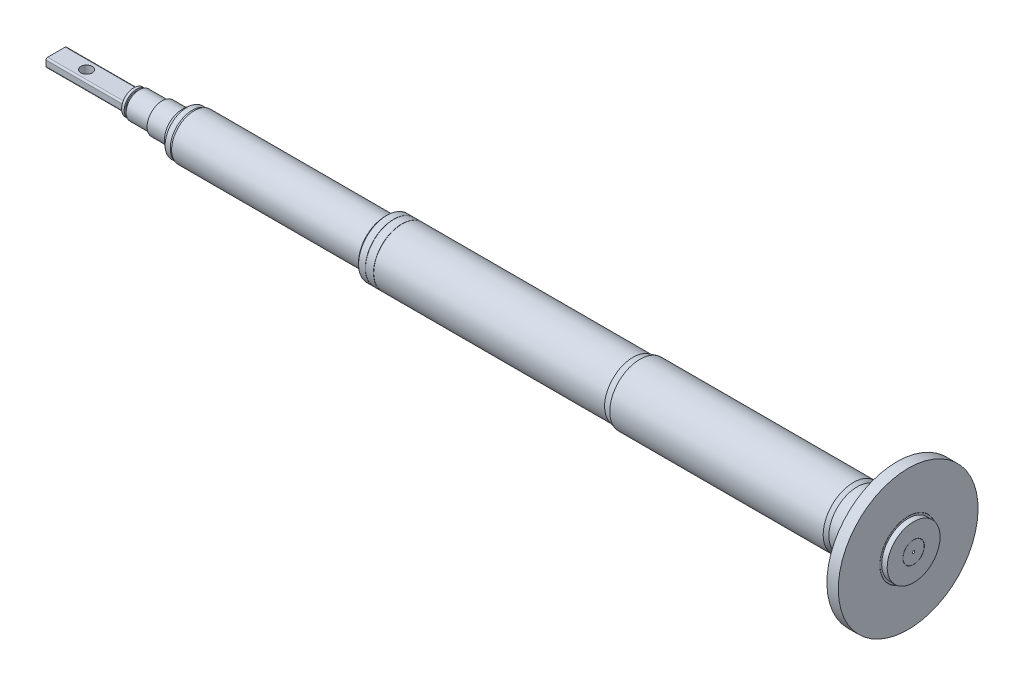
from build123d import *

# Parameters (mm, degrees)
SKETCH42_R                      = 0.3
TIP_FRONT_PROFILE_EXTRUDE_DEPTH = 20.5
SKETCH43_R                      = 1.5
TIP_TOP_PROFILE_CUT_DEPTH       = 125.190571804
SKETCH2_W                       = 2.116621235
SKETCH2_H                       = 1.45
SKETCH2_W_2                     = 0.8
SKETCH2_H_2                     = 0.7


with BuildPart() as part:
    # Sketch1 → FEI Body Revolve (revolve)
    with BuildSketch(Plane.XY):
        Polygon((-101.775, 3.5), (0.225, 3.5), (2.725, 6), (5.625, 6), (5.675, 4.5), (8.175, 4.5), (8.225, 6), (87.725, 6), (89.225, 7), (103.225, 7), (103.225, 2.85), (-101.775, 2.85), align=None)
        Polygon((5.724944491, 6.003331483), (5.771722207, 4.6), (8.078277793, 4.6), (8.125055509, 6.003331483), align=None)
        Polygon((-102.525, 2.8), (-102.525, 3.25), (-103.225, 3.25), (-103.225, 0.3), (103.225, 0.3), (103.225, 2.8), align=None)
    revolve(axis=Axis((103.225, 0, 0), (-1, 0, 0)))

    # Sketch42 → Tip - Front Profile Extrude (add)
    with BuildSketch(Plane.ZY.offset(103.225)):
        with BuildLine():
            Line((-2.320814105, 1.15), (2.320814105, 1.15))
            ThreePointArc((2.320814105, 1.15), (2.624294362, 1.024294362), (2.75, 0.720814105))
            Line((2.75, 0.720814105), (2.75, -0.720814105))
            ThreePointArc((2.75, -0.720814105), (2.624294362, -1.024294362), (2.320814105, -1.15))
            Line((2.320814105, -1.15), (-2.320814105, -1.15))
            ThreePointArc((-2.320814105, -1.15), (-2.624294362, -1.024294362), (-2.75, -0.720814105))
            Line((-2.75, -0.720814105), (-2.75, 0.720814105))
            ThreePointArc((-2.75, 0.720814105), (-2.624294362, 1.024294362), (-2.320814105, 1.15))
        make_face()
        with Locations(Location((0, 0, 0), (0, 0, 90))):
            Circle(SKETCH42_R, mode=Mode.SUBTRACT)
        with Locations(Location((0, 0, 0), (0, 0, 90))):
            Circle(SKETCH42_R)
    extrude(amount=TIP_FRONT_PROFILE_EXTRUDE_DEPTH)

    # Sketch43 → Tip - Top Profile Cut (cut, through all)
    with BuildSketch(Plane(origin=(0, 1.15, 0), x_dir=(1, 0, 0), z_dir=(0, 1, 0))):
        with Locations(Location((-115.725, 0, 0), (0, 0, 270))):
            Circle(SKETCH43_R)
    extrude(amount=-TIP_TOP_PROFILE_CUT_DEPTH, mode=Mode.SUBTRACT)


with BuildPart() as body_2:
    # Sketch2 → Nion Sleeve Revolve (revolve)
    with BuildSketch(Plane.XY):
        with BuildLine():
            Line((89.225, 7), (87.725, 6))
            Line((87.725, 6), (8.225, 6))
            Line((8.225, 6), (5.625, 6))
            Line((5.625, 6), (2.725, 6))
            Line((2.725, 6), (0.225, 3.5))
            Line((0.225, 3.5), (-95.725, 3.5))
            Line((-95.725, 3.5), (-95.725, 4))
            Line((-95.725, 4), (-90.545, 4))
            Line((-90.545, 4), (-90.545, 4.549461507))
            ThreePointArc((-90.545, 4.549461507), (-89.886715347, 5.221916317), (-89.144183588, 5.8))
            Line((-89.144183588, 5.8), (-87.774495484, 5.8))
            Line((-87.774495484, 5.8), (-87.225, 6))
            Line((-87.225, 6), (-32.225, 6))
            Line((-32.225, 6), (-32.225, 7.5))
            Line((-32.225, 7.5), (28.908974596, 7.5))
            Line((28.908974596, 7.5), (30.775, 8))
            Line((30.775, 8), (87.275, 8))
            Line((87.275, 8), (88.275, 7.5))
            Line((88.275, 7.5), (96.475, 7.5))
            Line((96.475, 7.5), (97.475, 8))
            Line((97.475, 8), (98.775, 8))
            Line((98.775, 8), (98.775, 10.45))
            Line((98.775, 10.45), (100.725, 10.45))
            Line((100.725, 10.45), (100.725, 7.45))
            Line((100.725, 7.45), (101.775, 7.45))
            Line((101.775, 7.45), (101.775, 7))
            Line((101.775, 7), (89.225, 7))
        make_face()
        with Locations((-33.333310618, 6.775)):
            Rectangle(SKETCH2_W, SKETCH2_H)
        Polygon((-34.441621235, 7.5), (-36.225, 7.5), (-36.725, 7), (-36.725, 6.8), (-35.875, 6.8), (-35.875, 6.05), (-34.441621235, 6.05), align=None)
        with Locations((-36.325, 6.4)):
            Rectangle(SKETCH2_W_2, SKETCH2_H_2)
        Polygon((101.775, 7.5), (100.775, 7.5), (100.775, 10.5), (98.775, 10.5), (98.775, 18.5), (101.775, 18.5), align=None)
    revolve(axis=Axis((200, 0, 0), (-1, 0, 0)))


solid = Compound([part.part, body_2.part])
